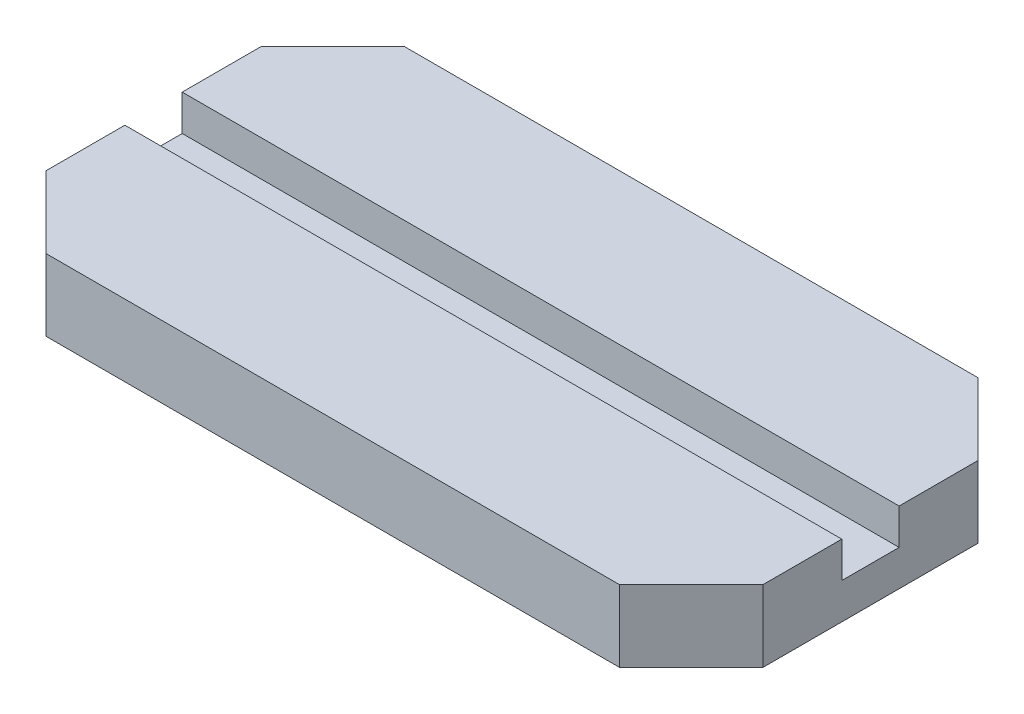
from build123d import *

# Parameters (mm, degrees)
SKETCH1_W           = 100
SKETCH1_H           = 50
BOSS_EXTRUDE1_DEPTH = 10
CHAMFER1_SIZE       = 10
SKETCH2_W           = 113.165724781
SKETCH2_H           = 8
CUT_EXTRUDE1_DEPTH  = 5


with BuildPart() as part:
    # Sketch1 → Boss-Extrude1 (new body)
    with BuildSketch(Plane(origin=(0, 0, 0), x_dir=(1, 0, 0), z_dir=(0, 1, 0))):
        Rectangle(SKETCH1_W, SKETCH1_H)
    extrude(amount=BOSS_EXTRUDE1_DEPTH)

    # Chamfer1
    chamfer1_edges = [part.edges().sort_by_distance(p)[0] for p in [
        (-50, 5, -25),
        (50, 5, -25),
        (50, 5, 25),
        (-50, 5, 25),
    ]]
    chamfer(chamfer1_edges, length=CHAMFER1_SIZE)

    # Sketch2 → Cut-Extrude1 (cut)
    with BuildSketch(Plane(origin=(0, 10, 0), x_dir=(1, 0, 0), z_dir=(0, 1, 0))):
        with Locations((-1.797960114, 0)):
            Rectangle(SKETCH2_W, SKETCH2_H)
    extrude(amount=-CUT_EXTRUDE1_DEPTH, mode=Mode.SUBTRACT)


solid = part.part
